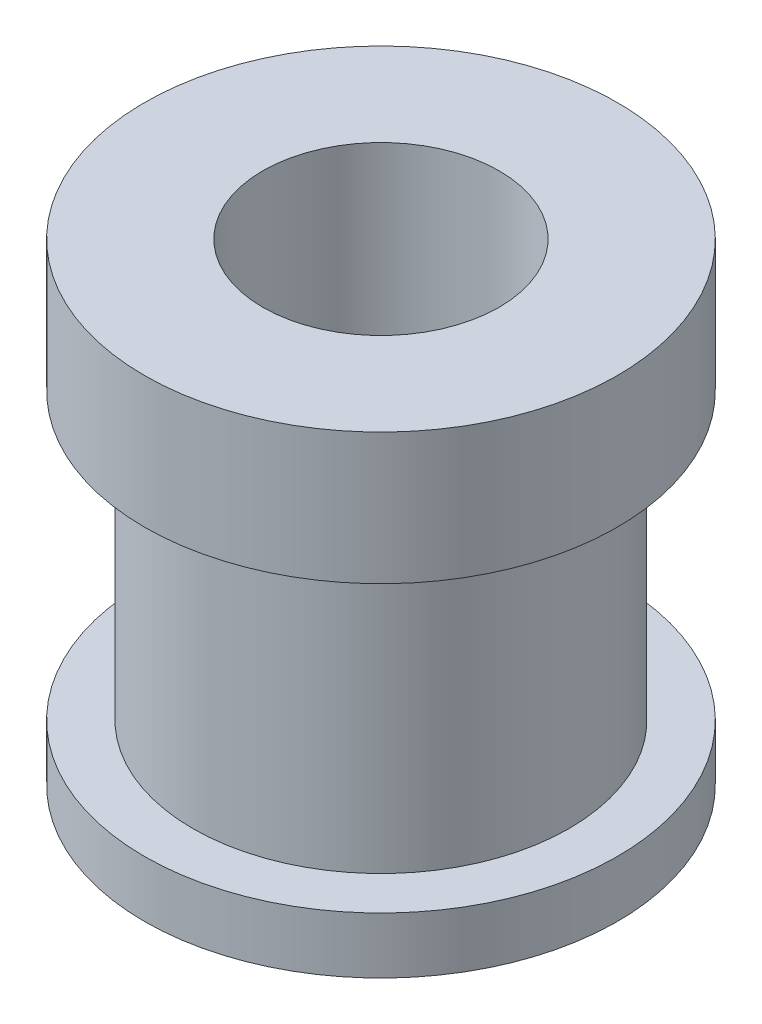
from build123d import *

# Parameters (mm, degrees)
BOSS_EXTRUDE1_DEPTH      = 8
BOSS_EXTRUDE1_DEPTH_BACK = 8
SKETCH1_R                = 8
CUT_EXTRUDE1_DEPTH       = 3.556
CUT_EXTRUDE1_DEPTH_BACK  = 6.094
SKETCH2_R                = 8
SKETCH2_R_2              = 6.36499997
SKETCH3_R                = 4
CUT_EXTRUDE2_DEPTH       = 20.595917942


with BuildPart() as part:
    # Sketch1 → Boss-Extrude1 (new, two sides: drawn at the far end of the back side and taken through both)
    with BuildSketch(Plane(origin=(0, 0, 0), x_dir=(1, 0, 0), z_dir=(0, 1, 0)).offset(-BOSS_EXTRUDE1_DEPTH_BACK)):
        Circle(SKETCH1_R)
    extrude(amount=BOSS_EXTRUDE1_DEPTH + BOSS_EXTRUDE1_DEPTH_BACK)

    # Sketch2 → Cut-Extrude1 (cut, two sides: drawn at the far end of the back side and taken through both)
    with BuildSketch(Plane(origin=(0, 0, 0), x_dir=(1, 0, 0), z_dir=(0, 1, 0)).offset(-CUT_EXTRUDE1_DEPTH_BACK)):
        Circle(SKETCH2_R)
        Circle(SKETCH2_R_2, mode=Mode.SUBTRACT)
    extrude(amount=CUT_EXTRUDE1_DEPTH + CUT_EXTRUDE1_DEPTH_BACK, mode=Mode.SUBTRACT)

    # Sketch3 → Cut-Extrude2 (cut, through all)
    with BuildSketch(Plane(origin=(0, 8, 0), x_dir=(1, 0, 0), z_dir=(0, 1, 0))):
        Circle(SKETCH3_R)
    extrude(amount=-CUT_EXTRUDE2_DEPTH, mode=Mode.SUBTRACT)


solid = part.part
